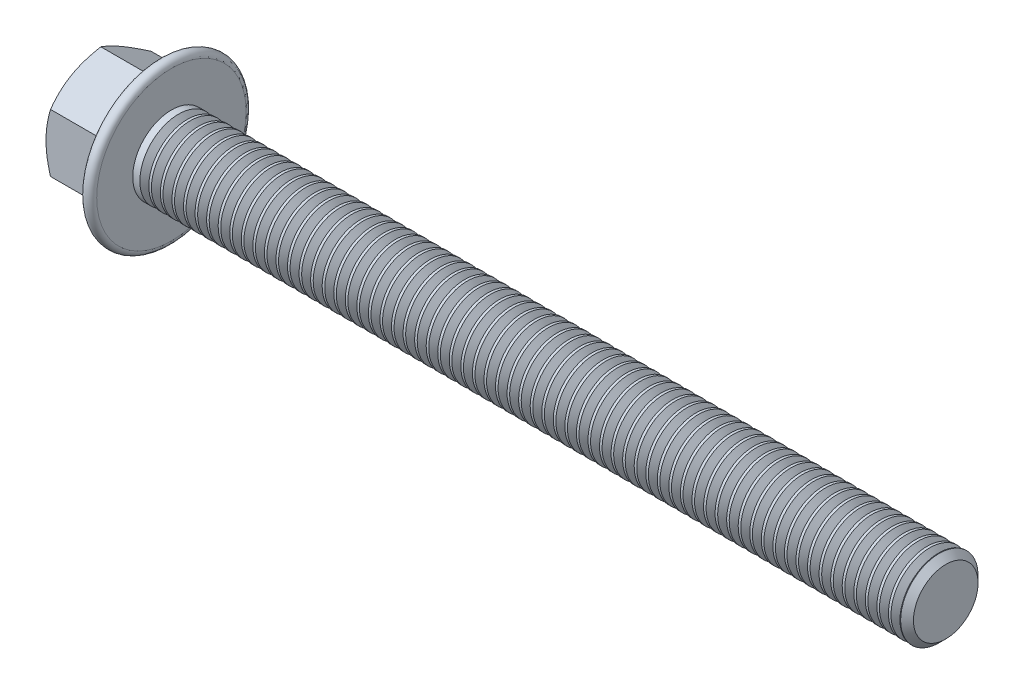
from build123d import *

# Parameters (mm, degrees)
BASEHEAD_DEPTH    = 9.7
FLANGEHEXFILLET_R = 0.2
THDSCHPAT_COUNT   = 66
THDSCHPAT_PITCH   = 1.492424242


with BuildPart() as part:
    # Sketch1 → BaseHead (new body)
    with BuildSketch(Plane(origin=(0, 0, 0), x_dir=(0, 0, -1), z_dir=(1, 0, 0))):
        Polygon((6.5, 3.75277675), (6.5, -3.75277675), (0, -7.505553499), (-6.5, -3.75277675), (-6.5, 3.75277675), (0, 7.505553499), align=None)
    extrude(amount=BASEHEAD_DEPTH)

    # BodySke → BaseBody (revolve)
    with BuildSketch(Plane.XY, mode=Mode.PRIVATE) as basebody_sk:
        Polygon((0, 0), (109.7, 0), (109.7, 4.172), (108.872, 5), (0, 5), align=None)
    revolve(basebody_sk.sketch.rotate(Axis((0, 0, 0), (1, 0, 0)), 90), axis=Axis((0, 0, 0), (1, 0, 0)))

    # Sketch3 → HeadChamfer (revolve, cut)
    with BuildSketch(Plane.XY, mode=Mode.PRIVATE) as headchamfer_sk:
        Polygon((0, 6.5), (3.46730793, 12.505553499), (3.46730793, 17.505553499), (-10, 17.505553499), (-10, 6.5), align=None)
    revolve(headchamfer_sk.sketch.rotate(Axis((0, 0, 0), (1, 0, 0)), 90), axis=Axis((0, 0, 0), (1, 0, 0)), mode=Mode.SUBTRACT)

    # Sketch4 → Flange (revolve)
    with BuildSketch(Plane.XY, mode=Mode.PRIVATE) as flange_sk:
        with BuildLine():
            Line((4.63955391, 0), (8.245230534, 9.906515107))
            ThreePointArc((8.245230534, 9.906515107), (9.080236133, 10.388605815), (9.7, 9.65))
            Line((9.7, 9.65), (9.7, 0))
            Line((9.7, 0), (4.63955391, 0))
        make_face()
    revolve(flange_sk.sketch.rotate(Axis((0, 0, 0), (1, 0, 0)), 90), axis=Axis((0, 0, 0), (1, 0, 0)))

    # FlangeHexFillet
    flangehexfillet_edges = [part.edges().sort_by_distance(p)[0] for p in [
        (7.005360433, 0, -6.5),
        (7.005360433, -5.629165125, -3.25),
        (7.102791368, 1.884573791, 6.5),
        (7.005360433, 5.629165125, 3.25),
        (7.005360433, 5.629165125, -3.25),
        (7.005360433, -5.629165125, 3.25),
        (7.102791368, -1.884573791, 6.5),
    ]]
    fillet(flangehexfillet_edges, radius=FLANGEHEXFILLET_R)

    # ThdSchSke → ThreadSchematic (revolve, cut)
    with BuildSketch(Plane.XY):
        Polygon((11.2, -4.172), (10.620228158, -5), (10.620228158, -6.25), (11.779771842, -6.25), (11.779771842, -5), align=None)
    threadschematic = revolve(axis=Axis((-3.175, 0, 0), (1, 0, 0)), mode=Mode.SUBTRACT)

    # ThdSchPat: ThreadSchematic ×66
    with Locations(*[(i * THDSCHPAT_PITCH, 0, 0) for i in range(1, THDSCHPAT_COUNT)]):
        add(threadschematic, mode=Mode.SUBTRACT)


solid = part.part
